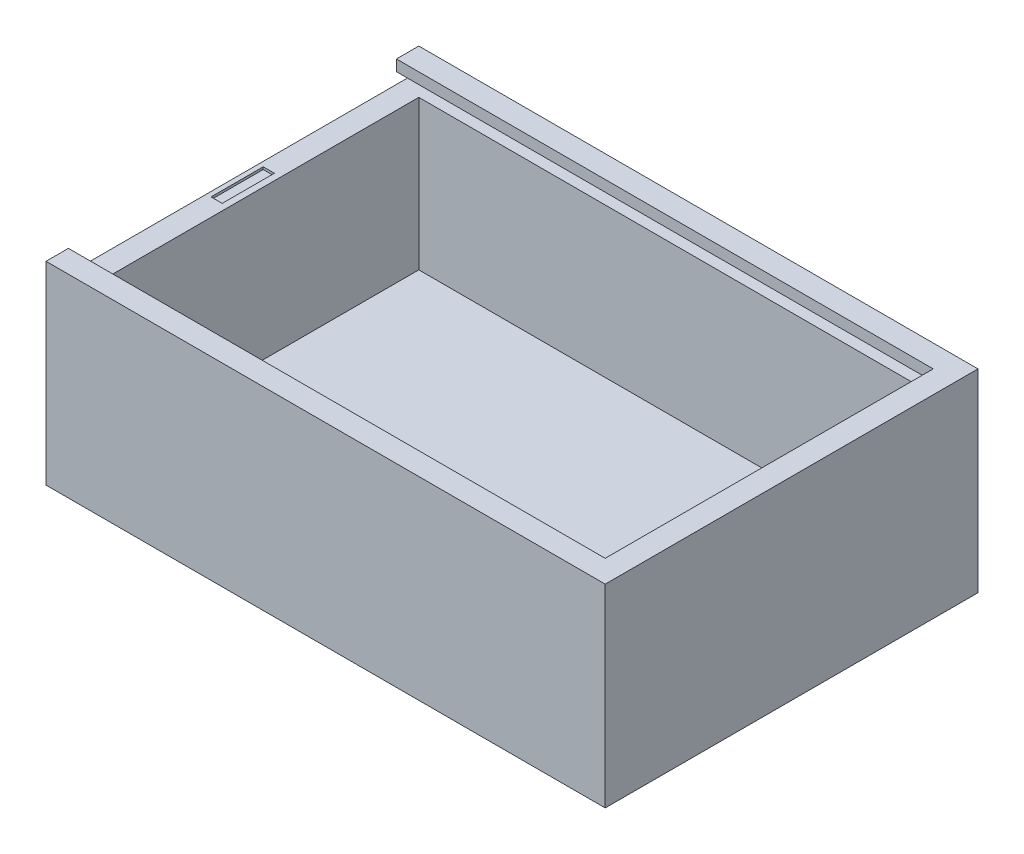
from build123d import *

# Parameters (mm, degrees)
CROQUIS1_W              = 75
CROQUIS1_H              = 50
CROQUIS1_W_2            = 69
CROQUIS1_H_2            = 44
SALIENTE_EXTRUIR1_DEPTH = 26
CROQUIS1_2_W            = 69
CROQUIS1_2_H            = 44
SALIENTE_EXTRUIR2_DEPTH = 3
CORTAR_EXTRUIR1_DEPTH   = 72
CROQUIS4_W              = 46.96
CROQUIS4_H              = 1.48
CORTAR_EXTRUIR2_DEPTH   = 1.5
CROQUIS7_W              = 1.5
CROQUIS7_H              = 7
CORTAR_EXTRUIR3_DEPTH   = 0.32


with BuildPart() as part:
    # Croquis1 → Saliente-Extruir1 (new body)
    with BuildSketch(Plane(origin=(0, 0, 0), x_dir=(1, 0, 0), z_dir=(0, 1, 0))):
        Rectangle(CROQUIS1_W, CROQUIS1_H)
        Rectangle(CROQUIS1_W_2, CROQUIS1_H_2, mode=Mode.SUBTRACT)
    extrude(amount=SALIENTE_EXTRUIR1_DEPTH)

    # Croquis1_2 → Saliente-Extruir2 (add)
    with BuildSketch(Plane(origin=(0, 0, 0), x_dir=(1, 0, 0), z_dir=(0, 1, 0))):
        Rectangle(CROQUIS1_2_W, CROQUIS1_2_H)
    extrude(amount=SALIENTE_EXTRUIR2_DEPTH)

    # Croquis3 → Cortar-Extruir1 (cut)
    with BuildSketch(Plane.ZY.offset(37.5)):
        Polygon((22, 26), (-22, 26), (-22, 24.52), (-23.48, 24.52), (-23.48, 23.04), (23.48, 23.04), (23.48, 24.52), (22, 24.52), align=None)
    extrude(amount=-CORTAR_EXTRUIR1_DEPTH, mode=Mode.SUBTRACT)

    # Croquis4 → Cortar-Extruir2 (cut)
    with BuildSketch(Plane.ZY.offset(-34.5)):
        with Locations((0, 23.78)):
            Rectangle(CROQUIS4_W, CROQUIS4_H)
    extrude(amount=-CORTAR_EXTRUIR2_DEPTH, mode=Mode.SUBTRACT)

    # Croquis7 → Cortar-Extruir3 (cut)
    with BuildSketch(Plane(origin=(0, 23.04, 0), x_dir=(1, 0, 0), z_dir=(0, 1, 0))):
        with Locations((-36.12, 0)):
            Rectangle(CROQUIS7_W, CROQUIS7_H)
    extrude(amount=-CORTAR_EXTRUIR3_DEPTH, mode=Mode.SUBTRACT)


solid = part.part
